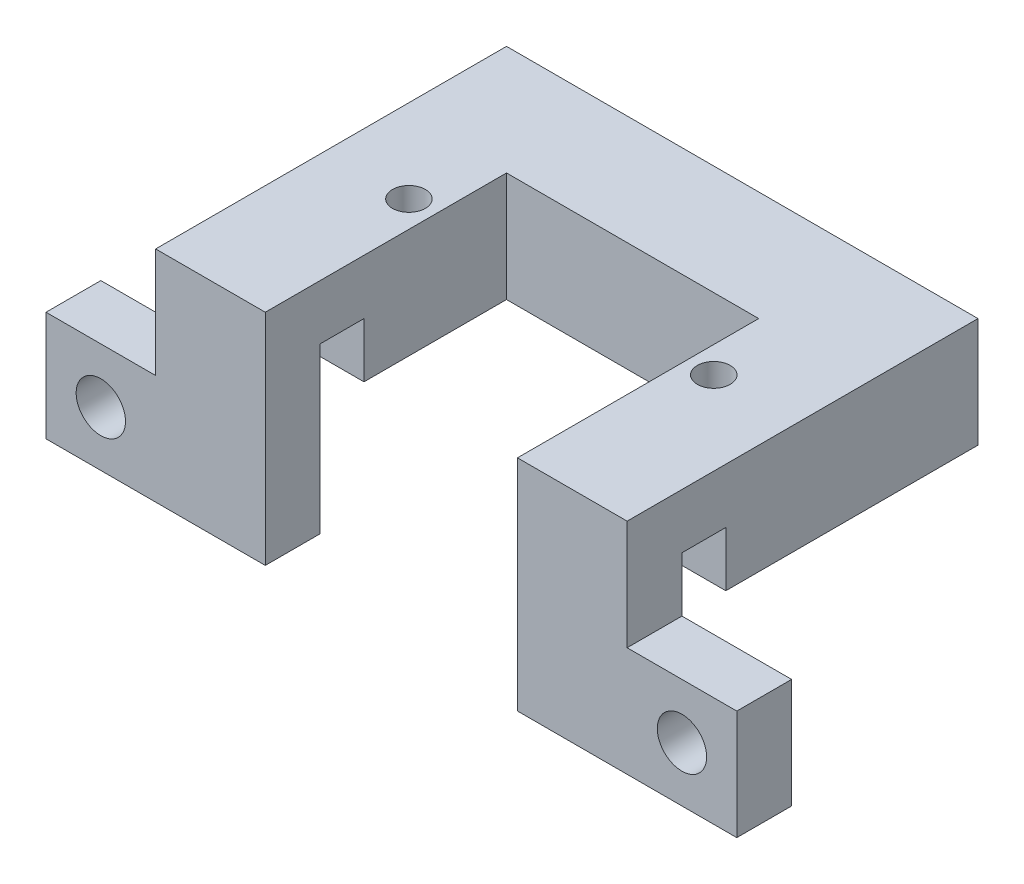
from build123d import *

# Parameters (mm, degrees)
RESSALTO_EXTRUS_O1_DEPTH = 10
ESBO_O2_R                = 1.5
CORTE_EXTRUS_O1_DEPTH    = 11
RESSALTO_EXTRUS_O2_DEPTH = 10
ESBO_O4_W                = 4
ESBO_O4_H                = 5
CORTE_EXTRUS_O4_DEPTH    = 44
ESBO_O5_W                = 10
ESBO_O5_H                = 5
RESSALTO_EXTRUS_O3_DEPTH = 10
ESBO_O6_W                = 10
ESBO_O6_H                = 10
RESSALTO_EXTRUS_O4_DEPTH = 5
FURO_COM_FOLGA_DE_M41_D  = 4.5


with BuildPart() as part:
    # Esboço1 → Ressalto-extrusão1 (new body)
    with BuildSketch(Plane(origin=(0, 0, 0), x_dir=(1, 0, 0), z_dir=(0, 1, 0))):
        Polygon((-21.5, 0), (-21.5, -23), (-11.5, -23), (-11.5, -10), (11.5, -10), (11.5, -23), (21.5, -23), (21.5, 0), align=None)
    extrude(amount=RESSALTO_EXTRUS_O1_DEPTH)

    # Esboço2 → Corte-extrusão1 (cut, through all)
    with BuildSketch(Plane(origin=(0, 10, 0), x_dir=(1, 0, 0), z_dir=(0, 1, 0))):
        with Locations((-13.9, -16.5)):
            Circle(ESBO_O2_R)
        with Locations((13.9, -16.5)):
            Circle(ESBO_O2_R)
    extrude(amount=-CORTE_EXTRUS_O1_DEPTH, mode=Mode.SUBTRACT)

    # Esboço3 → Ressalto-extrusão2 (add)
    with BuildSketch(Plane(origin=(0, 10, 0), x_dir=(1, 0, 0), z_dir=(0, 1, 0))):
        Polygon((-21.5, -23), (-21.5, -27), (-21.5, -32), (-11.5, -32), (-11.5, -27), (-11.5, -23), align=None)
        Polygon((11.5, -23), (21.5, -23), (21.5, -27), (21.5, -32), (11.5, -32), (11.5, -27), align=None)
    extrude(amount=-RESSALTO_EXTRUS_O2_DEPTH)

    # Esboço4 → Corte-extrusão4 (cut, through all)
    with BuildSketch(Plane(origin=(21.5, 0, 0), x_dir=(0, 0, -1), z_dir=(1, 0, 0))):
        with Locations((-25, 2.5)):
            Rectangle(ESBO_O4_W, ESBO_O4_H)
    extrude(amount=-CORTE_EXTRUS_O4_DEPTH, mode=Mode.SUBTRACT)

    # Esboço5 → Ressalto-extrusão3 (add)
    with BuildSketch(Plane.XZ):
        with Locations((-16.5, 29.5)):
            Rectangle(ESBO_O5_W, ESBO_O5_H)
        with Locations((16.5, 29.5)):
            Rectangle(ESBO_O5_W, ESBO_O5_H)
    extrude(amount=RESSALTO_EXTRUS_O3_DEPTH)

    # Esboço6 → Ressalto-extrusão4 (add)
    with BuildSketch(Plane.XY.offset(32)):
        with Locations((-26.5, -5)):
            Rectangle(ESBO_O6_W, ESBO_O6_H)
        with Locations((26.5, -5)):
            Rectangle(ESBO_O6_W, ESBO_O6_H)
    extrude(amount=-RESSALTO_EXTRUS_O4_DEPTH)

    # Furo com folga de M41 (through all)
    with Locations(Plane(origin=(-26.5, -5, 32), x_dir=(1, 0, 0), z_dir=(0, 0, 1))):
        with Locations((0, 0), (53, 0)):
            Hole(FURO_COM_FOLGA_DE_M41_D / 2)


solid = part.part
